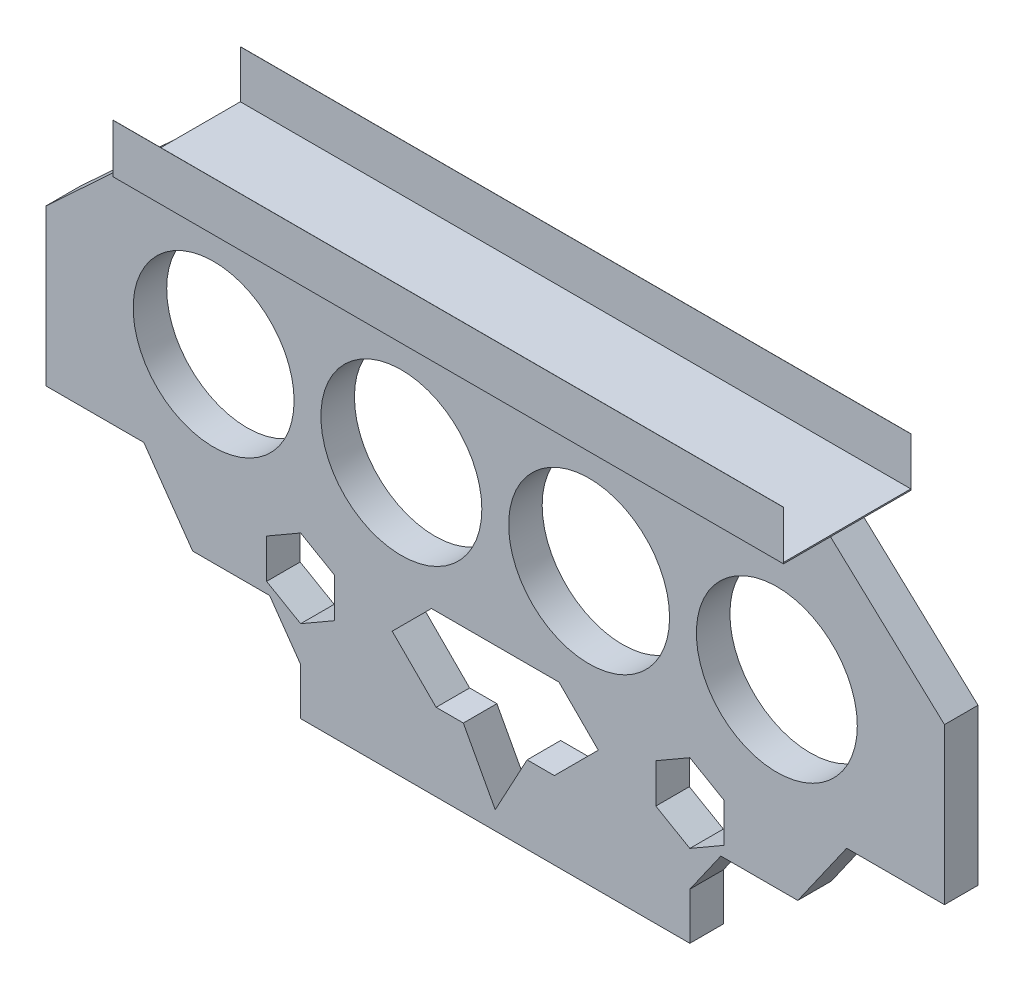
from build123d import *

# Parameters (mm, degrees)
SKETCH1_W           = 134
SKETCH1_H           = 63
BOSS_EXTRUDE1_DEPTH = 5
SKETCH3_R           = 12
CUT_EXTRUDE1_DEPTH  = 10
CUT_EXTRUDE2_DEPTH  = 10
BOSS_EXTRUDE2_DEPTH = 100


with BuildPart() as part:
    # Sketch1 → Boss-Extrude1 (new body)
    with BuildSketch(Plane.XY):
        Rectangle(SKETCH1_W, SKETCH1_H)
    extrude(amount=-BOSS_EXTRUDE1_DEPTH)

    # Sketch3 → Cut-Extrude1 (cut)
    with BuildSketch(Plane.XY):
        with Locations((-42, 9.071273883)):
            Circle(SKETCH3_R)
        with Locations((-14, 9.071273883)):
            Circle(SKETCH3_R)
        with Locations((14, 9.071273883)):
            Circle(SKETCH3_R)
        with Locations((42, 9.071273883)):
            Circle(SKETCH3_R)
    extrude(amount=-CUT_EXTRUDE1_DEPTH, mode=Mode.SUBTRACT)

    # Sketch4 → Cut-Extrude2 (cut)
    with BuildSketch(Plane.XY):
        Polygon((-67, -7.520628775), (-52.411804658, -7.520628775), (-45.12377265, -17.909951), (-33.648998849, -17.909951), (-29.023524966, -24.503711642), (-29.023524966, -31.5), (-67, -31.5), align=None)
        Polygon((67, -7.520628775), (67, -31.5), (29.023524966, -31.5), (29.023524966, -24.503711642), (33.648998849, -17.909951), (45.12377265, -17.909951), (52.411804658, -7.520628775), align=None)
        Polygon((-50, 31.5), (-67, 15.739047849), (-67, 31.5), align=None)
        Polygon((67, 15.739047849), (67, 31.5), (50, 31.5), align=None)
        Polygon((9.511401459, -7.520628775), (-9.511401459, -7.520628775), (-15.370004361, -13.379231677), (-8.815992906, -19.933243133), (-4.75570073, -19.933243133), (-2.290700849, -24.503711642), (0, -28.751004381), (2.290700849, -24.503711642), (4.75570073, -19.933243133), (8.815992906, -19.933243133), (15.370004361, -13.379231677), align=None)
        Polygon((-34.097223909, -10.449930226), (-29.023524966, -7.520628775), (-23.949826022, -10.449930226), (-23.949826022, -16.308533128), (-29.023524966, -19.237834579), (-34.097223909, -16.308533128), align=None)
        Polygon((29.023524966, -7.520628775), (23.949826022, -10.449930226), (23.949826022, -16.308533128), (29.023524966, -19.237834579), (34.097223909, -16.308533128), (34.097223909, -10.449930226), align=None)
    extrude(amount=-CUT_EXTRUDE2_DEPTH, mode=Mode.SUBTRACT)

    # Sketch5 → Boss-Extrude2 (add)
    with BuildSketch(Plane(origin=(50, 0, 0), x_dir=(0, 0, -1), z_dir=(1, 0, 0))):
        Polygon((5, 31.5), (12, 31.5), (12, 38.804238111), (11.980580676, 38.804238111), (11.980580676, 31.696116135), (5.980580676, 31.696116135), (-0.980580676, 31.696116135), (-6.980580676, 31.696116135), (-6.980580676, 38.804238111), (-7, 38.804238111), (-7, 31.5), (0, 31.5), align=None)
    extrude(amount=-BOSS_EXTRUDE2_DEPTH)


solid = part.part
